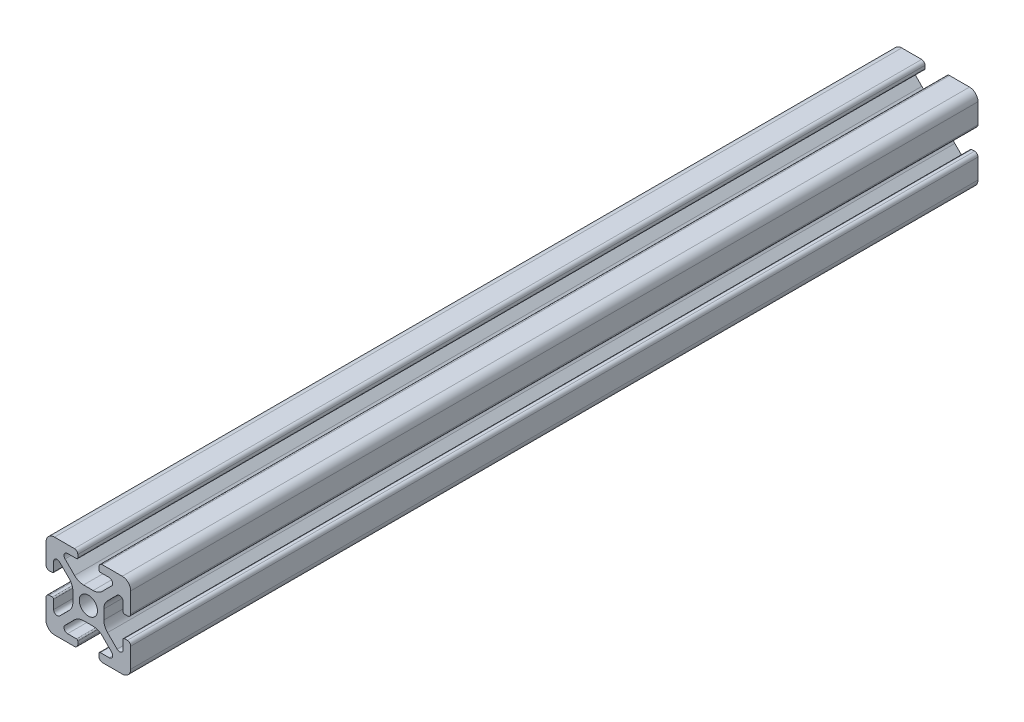
from build123d import *

# Parameters (mm, degrees)
SKETCH4_W              = 20
SKETCH4_H              = 20
BODY_DEPTH             = 200
SKETCH16_OUTSIDE_W     = 62.398
SKETCH16_OUTSIDE_H     = 62.398
SKETCH16_OUTSIDE_R     = 2.15
CUT_PROFILE_DEPTH      = 26
CUT_PROFILE_DEPTH_BACK = 176


with BuildPart() as part:
    # Sketch4 → Body (new body)
    with BuildSketch(Plane.XY.offset(25)):
        Rectangle(SKETCH4_W, SKETCH4_H)
    extrude(amount=-BODY_DEPTH)

    # Sketch16 outside → Cut-Profile (cut, two sides)
    with BuildSketch(Plane.XY) as cut_profile_sk:
        Rectangle(SKETCH16_OUTSIDE_W, SKETCH16_OUTSIDE_H)
        with BuildLine():
            Line((4.917588389, -8.199999991), (2.799999989, -8.199999991))
            ThreePointArc((2.799999989, -8.199999991), (2.587867955, -8.287867957), (2.499999989, -8.499999991))
            Line((2.499999989, -8.499999991), (2.499999989, -9.199999991))
            ThreePointArc((2.499999989, -9.199999991), (2.734314564, -9.765685416), (3.299999989, -9.999999991))
            Line((3.299999989, -9.999999991), (7.999999989, -9.999999991))
            ThreePointArc((7.999999989, -9.999999991), (9.414213552, -9.414213554), (9.999999989, -7.999999991))
            Line((9.999999989, -7.999999991), (9.999999989, -3.299999991))
            ThreePointArc((9.999999989, -3.299999991), (9.765685414, -2.734314566), (9.199999989, -2.499999991))
            Line((9.199999989, -2.499999991), (8.499999989, -2.499999991))
            ThreePointArc((8.499999989, -2.499999991), (8.287867955, -2.587867957), (8.199999989, -2.799999991))
            Line((8.199999989, -2.799999991), (8.199999989, -4.917588391))
            ThreePointArc((8.199999989, -4.917588391), (7.686138511, -5.686636441), (6.778984485, -5.506192286))
            Line((6.778984485, -5.506192286), (4.528679645, -3.255887446))
            ThreePointArc((4.528679645, -3.255887446), (3.878361392, -2.282617401), (3.64999999, -1.134567106))
            Line((3.64999999, -1.134567106), (3.64999999, 1.134567104))
            ThreePointArc((3.64999999, 1.134567104), (3.878361393, 2.282617402), (4.528679647, 3.255887448))
            Line((4.528679647, 3.255887448), (6.778984487, 5.506192288))
            ThreePointArc((6.778984487, 5.506192288), (7.686138506, 5.686636442), (8.199999981, 4.917588398))
            Line((8.199999981, 4.917588398), (8.199999981, 2.799999998))
            ThreePointArc((8.199999981, 2.799999998), (8.287867946, 2.587867964), (8.499999981, 2.499999998))
            Line((8.499999981, 2.499999998), (9.199999981, 2.499999998))
            ThreePointArc((9.199999981, 2.499999998), (9.765685406, 2.734314573), (9.999999981, 3.299999998))
            Line((9.999999981, 3.299999998), (9.999999981, 7.999999998))
            ThreePointArc((9.999999981, 7.999999998), (9.414213543, 9.41421356), (7.999999981, 9.999999998))
            Line((7.999999981, 9.999999998), (3.299999981, 9.999999998))
            ThreePointArc((3.299999981, 9.999999998), (2.734314556, 9.765685423), (2.499999981, 9.199999998))
            Line((2.499999981, 9.199999998), (2.499999981, 8.499999998))
            ThreePointArc((2.499999981, 8.499999998), (2.587867946, 8.287867964), (2.799999981, 8.199999998))
            Line((2.799999981, 8.199999998), (4.917588381, 8.199999998))
            ThreePointArc((4.917588381, 8.199999998), (5.68663643, 7.68613852), (5.506192275, 6.778984494))
            Line((5.506192275, 6.778984494), (3.255887435, 4.528679654))
            ThreePointArc((3.255887435, 4.528679654), (2.28261739, 3.878361401), (1.134567095, 3.649999999))
            Line((1.134567095, 3.649999999), (-1.134567115, 3.649999999))
            ThreePointArc((-1.134567115, 3.649999999), (-2.282617412, 3.878361401), (-3.255887459, 4.528679655))
            Line((-3.255887459, 4.528679655), (-5.506192299, 6.778984495))
            ThreePointArc((-5.506192299, 6.778984495), (-5.686636452, 7.686138515), (-4.917588409, 8.199999989))
            Line((-4.917588409, 8.199999989), (-2.800000009, 8.199999989))
            ThreePointArc((-2.800000009, 8.199999989), (-2.587867974, 8.287867955), (-2.500000009, 8.499999989))
            Line((-2.500000009, 8.499999989), (-2.500000009, 9.199999989))
            ThreePointArc((-2.500000009, 9.199999989), (-2.734314584, 9.765685414), (-3.300000009, 9.999999989))
            Line((-3.300000009, 9.999999989), (-8.000000009, 9.999999989))
            ThreePointArc((-8.000000009, 9.999999989), (-9.414213571, 9.414213552), (-10.000000009, 7.999999989))
            Line((-10.000000009, 7.999999989), (-10.000000009, 3.299999989))
            ThreePointArc((-10.000000009, 3.299999989), (-9.765685434, 2.734314564), (-9.200000009, 2.499999989))
            Line((-9.200000009, 2.499999989), (-8.500000009, 2.499999989))
            ThreePointArc((-8.500000009, 2.499999989), (-8.287867974, 2.587867955), (-8.200000009, 2.799999989))
            Line((-8.200000009, 2.799999989), (-8.200000009, 4.917588389))
            ThreePointArc((-8.200000009, 4.917588389), (-7.686138531, 5.686636438), (-6.778984504, 5.506192284))
            Line((-6.778984504, 5.506192284), (-4.528679664, 3.255887444))
            ThreePointArc((-4.528679664, 3.255887444), (-3.878361412, 2.282617399), (-3.650000009, 1.134567104))
            Line((-3.650000009, 1.134567104), (-3.650000009, -1.134567106))
            ThreePointArc((-3.650000009, -1.134567106), (-3.878361412, -2.282617404), (-4.528679666, -3.25588745))
            Line((-4.528679666, -3.25588745), (-6.778984506, -5.50619229))
            ThreePointArc((-6.778984506, -5.50619229), (-7.686138526, -5.686636444), (-8.2, -4.9175884))
            Line((-8.2, -4.9175884), (-8.2, -2.8))
            ThreePointArc((-8.2, -2.8), (-8.287867966, -2.587867966), (-8.5, -2.5))
            Line((-8.5, -2.5), (-9.2, -2.5))
            ThreePointArc((-9.2, -2.5), (-9.765685425, -2.734314575), (-10, -3.3))
            Line((-10, -3.3), (-10, -8))
            ThreePointArc((-10, -8), (-9.414213562, -9.414213562), (-8, -10))
            Line((-8, -10), (-3.3, -10))
            ThreePointArc((-3.3, -10), (-2.734314575, -9.765685425), (-2.5, -9.2))
            Line((-2.5, -9.2), (-2.5, -8.5))
            ThreePointArc((-2.5, -8.5), (-2.587867966, -8.287867966), (-2.8, -8.2))
            Line((-2.8, -8.2), (-4.9175884, -8.2))
            ThreePointArc((-4.9175884, -8.2), (-5.686636449, -7.686138522), (-5.506192294, -6.778984496))
            Line((-5.506192294, -6.778984496), (-3.255887454, -4.528679656))
            ThreePointArc((-3.255887454, -4.528679656), (-2.282617409, -3.878361403), (-1.134567114, -3.650000001))
            Line((-1.134567114, -3.650000001), (1.134567096, -3.650000001))
            ThreePointArc((1.134567096, -3.650000001), (2.282617393, -3.878361403), (3.255887439, -4.528679657))
            Line((3.255887439, -4.528679657), (5.506192279, -6.778984497))
            ThreePointArc((5.506192279, -6.778984497), (5.686636433, -7.686138517), (4.917588389, -8.199999991))
        make_face(mode=Mode.SUBTRACT)
        Circle(SKETCH16_OUTSIDE_R)
    extrude(amount=CUT_PROFILE_DEPTH, mode=Mode.SUBTRACT)
    extrude(cut_profile_sk.sketch, amount=-CUT_PROFILE_DEPTH_BACK, mode=Mode.SUBTRACT)


solid = part.part
